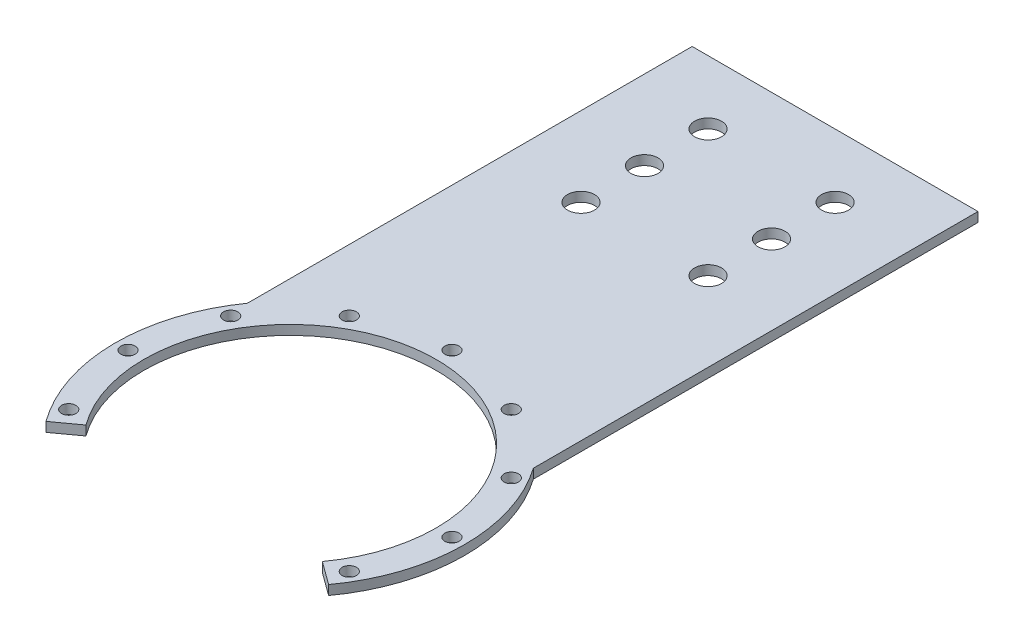
from build123d import *

# Parameters (mm, degrees)
SKETCH1_R               = 55
BOSS_EXTRUDE1_DEPTH     = 3
SKETCH2_W               = 90
SKETCH2_H               = 140
BOSS_EXTRUDE2_DEPTH     = 3
SKETCH4_R               = 46
CUT_EXTRUDE2_DEPTH      = 1
CUT_EXTRUDE2_DEPTH_BACK = 4
CUT_EXTRUDE5_START      = -4
CUT_EXTRUDE5_DEPTH      = 5
CUT_EXTRUDE3_START      = -4
SKETCH5_R               = 2.25
CUT_EXTRUDE3_DEPTH      = 5
CIRPATTERN1_COUNT       = 12
CUT_EXTRUDE4_START      = -4
SKETCH6_R               = 4.25
CUT_EXTRUDE4_DEPTH      = 5
LPATTERN1_COUNT         = 3
LPATTERN1_PITCH         = 20


with BuildPart() as part:
    # Sketch1 → Boss-Extrude1 (new body)
    with BuildSketch(Plane(origin=(0, 0, 0), x_dir=(1, 0, 0), z_dir=(0, 1, 0))):
        Circle(SKETCH1_R)
    extrude(amount=BOSS_EXTRUDE1_DEPTH)

    # Sketch2 → Boss-Extrude2 (add)
    with BuildSketch(Plane(origin=(0, 0, 0), x_dir=(1, 0, 0), z_dir=(0, 1, 0))):
        with Locations((0, 101.622776602)):
            Rectangle(SKETCH2_W, SKETCH2_H)
    extrude(amount=BOSS_EXTRUDE2_DEPTH)

    # Sketch4 → Cut-Extrude2 (cut, two sides)
    with BuildSketch(Plane(origin=(0, 3, 0), x_dir=(1, 0, 0), z_dir=(0, 1, 0))) as cut_extrude2_sk:
        Circle(SKETCH4_R)
    extrude(amount=CUT_EXTRUDE2_DEPTH, mode=Mode.SUBTRACT)
    extrude(cut_extrude2_sk.sketch, amount=-CUT_EXTRUDE2_DEPTH_BACK, mode=Mode.SUBTRACT)

    # Sketch7 → Cut-Extrude5 (cut)
    with BuildSketch(Plane(origin=(0, 3, 0), x_dir=(1, 0, 0), z_dir=(0, 1, 0)).offset(CUT_EXTRUDE5_START)):
        with BuildLine():
            Line((0, 0), (0, -55))
            ThreePointArc((0, -55), (-24.969477486, -49.00535883), (-44.495934691, -32.328188876))
            Line((-44.495934691, -32.328188876), (0, 0))
        make_face()
    cut_extrude5 = extrude(amount=CUT_EXTRUDE5_DEPTH, mode=Mode.SUBTRACT)

    # Mirror1: Cut-Extrude5 across plane
    add(cut_extrude5.mirror(Plane(origin=(0, 0, 0), x_dir=(0, 0, 1), z_dir=(1, 0, 0))), mode=Mode.SUBTRACT)

    # Sketch5 → Cut-Extrude3 (cut)
    with BuildSketch(Plane(origin=(0, 3, 0), x_dir=(1, 0, 0), z_dir=(0, 1, 0)).offset(CUT_EXTRUDE3_START)):
        with Locations((0, 51)):
            Circle(SKETCH5_R)
    cut_extrude3 = extrude(amount=CUT_EXTRUDE3_DEPTH, mode=Mode.SUBTRACT)

    # CirPattern1: Cut-Extrude3 ×12 about axis
    cirpattern1_axis = Axis((0, 0, 0), (0, 1, 0))
    for i in range(1, CIRPATTERN1_COUNT):
        add(cut_extrude3.rotate(cirpattern1_axis, i * 360 / CIRPATTERN1_COUNT), mode=Mode.SUBTRACT)

    # Sketch6 → Cut-Extrude4 (cut)
    with BuildSketch(Plane(origin=(0, 3, 0), x_dir=(1, 0, 0), z_dir=(0, 1, 0)).offset(CUT_EXTRUDE4_START)):
        with Locations((20, 151.622776602)):
            Circle(SKETCH6_R)
        with Locations((-20, 151.622776602)):
            Circle(SKETCH6_R)
    cut_extrude4 = extrude(amount=CUT_EXTRUDE4_DEPTH, mode=Mode.SUBTRACT)

    # LPattern1: Cut-Extrude4 ×3
    with Locations(*[(0, 0, i * LPATTERN1_PITCH) for i in range(1, LPATTERN1_COUNT)]):
        add(cut_extrude4, mode=Mode.SUBTRACT)


solid = part.part
